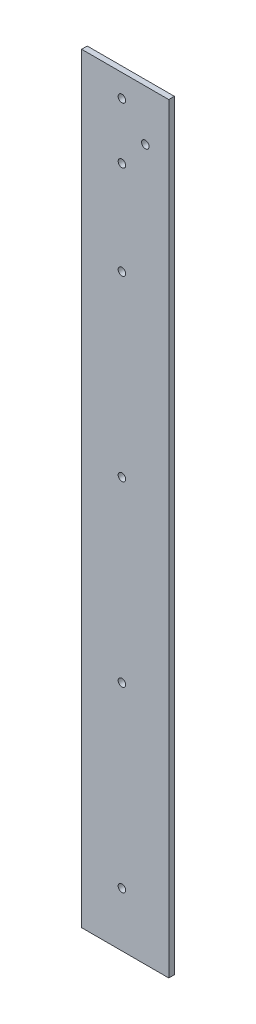
from build123d import *

# Parameters (mm, degrees)
SKETCH1_W           = 46.5
SKETCH1_H           = 406
SKETCH1_R           = 2
BOSS_EXTRUDE1_DEPTH = 3


with BuildPart() as part:
    # Sketch1 → Boss-Extrude1 (new body)
    with BuildSketch(Plane.XY):
        with Locations((0.557942617, 0.278971309)):
            Rectangle(SKETCH1_W, SKETCH1_H)
        with Locations((-1.192057383, 191.278971309)):
            Circle(SKETCH1_R, mode=Mode.SUBTRACT)
        with Locations((11.307942617, 176.278971308)):
            Circle(SKETCH1_R, mode=Mode.SUBTRACT)
        with Locations((-1.192057383, 161.278971308)):
            Circle(SKETCH1_R, mode=Mode.SUBTRACT)
        with Locations((-1.192057383, 111.278971308)):
            Circle(SKETCH1_R, mode=Mode.SUBTRACT)
        with Locations((-1.192057383, 16.278971308)):
            Circle(SKETCH1_R, mode=Mode.SUBTRACT)
        with Locations((-1.192057383, -78.721028692)):
            Circle(SKETCH1_R, mode=Mode.SUBTRACT)
        with Locations((-1.192057383, -173.721028692)):
            Circle(SKETCH1_R, mode=Mode.SUBTRACT)
    extrude(amount=BOSS_EXTRUDE1_DEPTH)


solid = part.part
